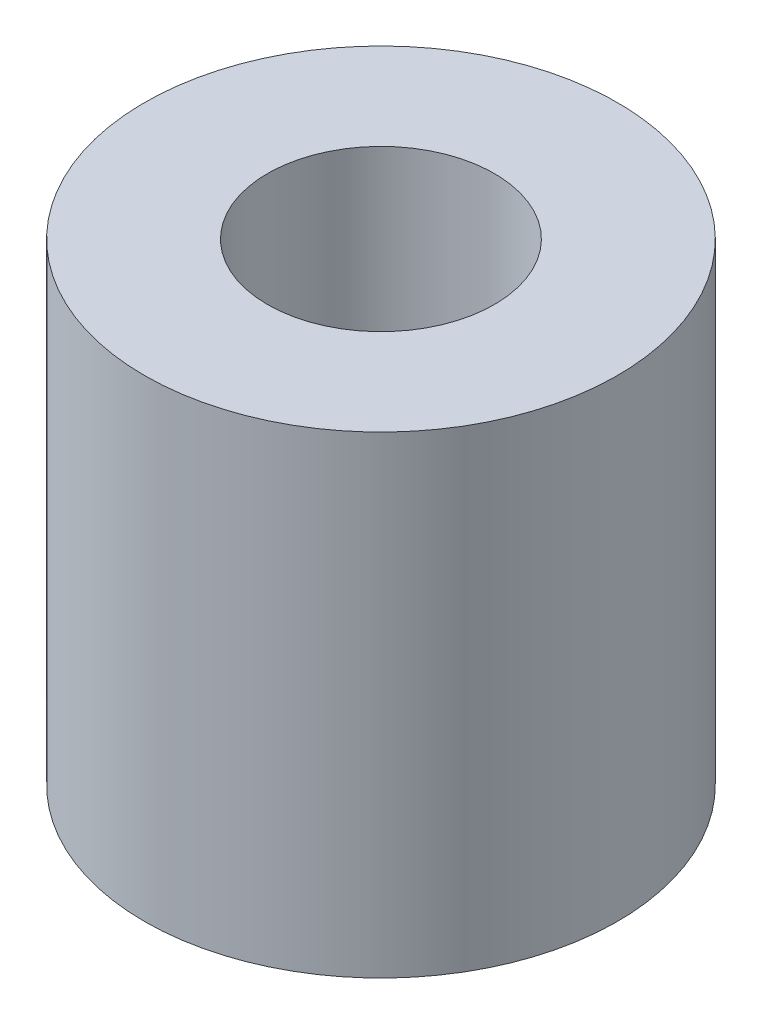
from build123d import *

# Parameters (mm, degrees)
SKETCH1_R      = 3.175
SKETCH1_R_2    = 1.524
EXTRUDE1_DEPTH = 6.35


with BuildPart() as part:
    # Sketch1 → Extrude1 (new body)
    with BuildSketch(Plane(origin=(0, 0, 0), x_dir=(1, 0, 0), z_dir=(0, 1, 0))):
        with Locations(Location((0, 0, 0), (0, 0, 270))):  # turned: the seam where the file's is
            Circle(SKETCH1_R)
        with Locations(Location((0, 0, 0), (0, 0, 270))):  # turned: the seam where the file's is
            Circle(SKETCH1_R_2, mode=Mode.SUBTRACT)
    extrude(amount=EXTRUDE1_DEPTH)


solid = part.part
